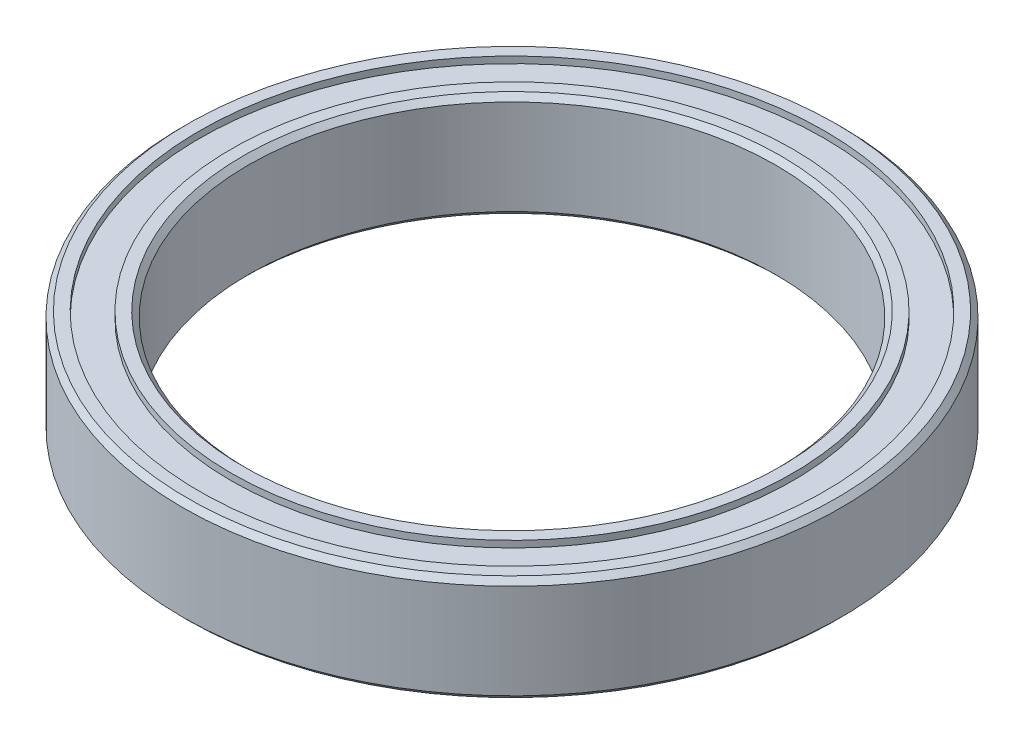
from build123d import *

# Parameters (mm, degrees)
FASE1_SIZE = 0.2


with BuildPart() as part:
    # Skizze2 → Rotation2 (revolve)
    with BuildSketch(Plane(origin=(0, 0, 0), x_dir=(0, 0, -1), z_dir=(1, 0, 0))):
        Polygon((-12.5, 2), (-12.5, -2), (-11.85, -2), (-11.85, -1.75), (-10.65, -1.75), (-10.65, -2), (-10, -2), (-10, 2), (-10.65, 2), (-10.65, 1.75), (-11.85, 1.75), (-11.85, 2), align=None)
    revolve(axis=Axis((0, -18.122913865, 0), (0, 1, 0)))

    # Fase1
    fase1_edges = [part.edges().sort_by_distance(p)[0] for p in [
        (0, 2, -10),
        (0, -2, -10),
        (0, 2, -12.5),
        (0, -2, -12.5),
    ]]
    chamfer(fase1_edges, length=FASE1_SIZE)


solid = part.part
